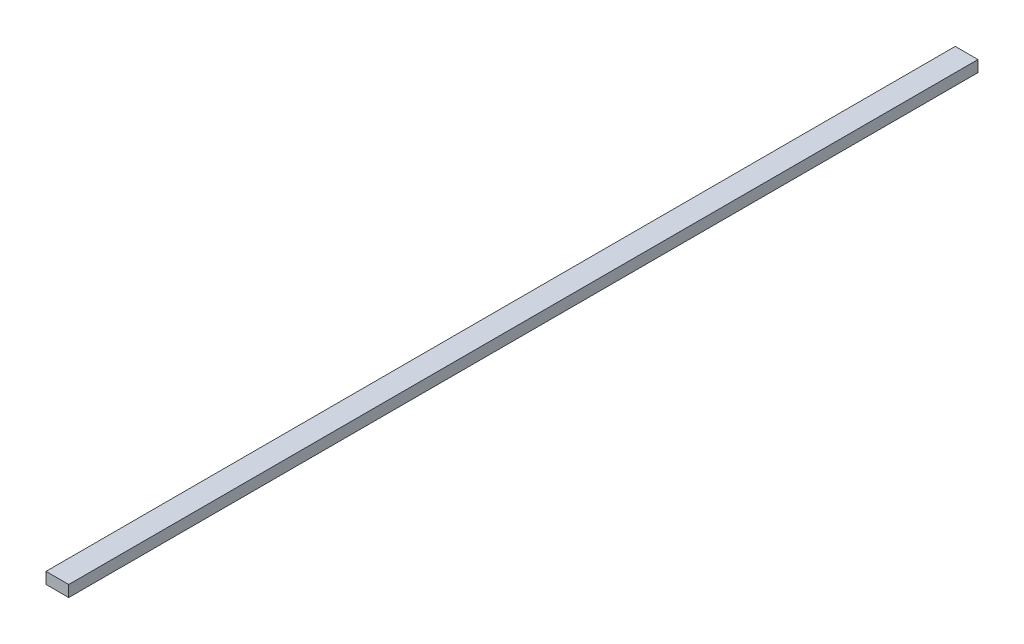
from build123d import *

# Parameters (mm, degrees)
SKETCH1_W           = 12.5
SKETCH1_H           = 6.25
BOSS_EXTRUDE1_DEPTH = 500


with BuildPart() as part:
    # Sketch1 → Boss-Extrude1 (new body)
    with BuildSketch(Plane.XY):
        Rectangle(SKETCH1_W, SKETCH1_H)
    extrude(amount=BOSS_EXTRUDE1_DEPTH)


solid = part.part
